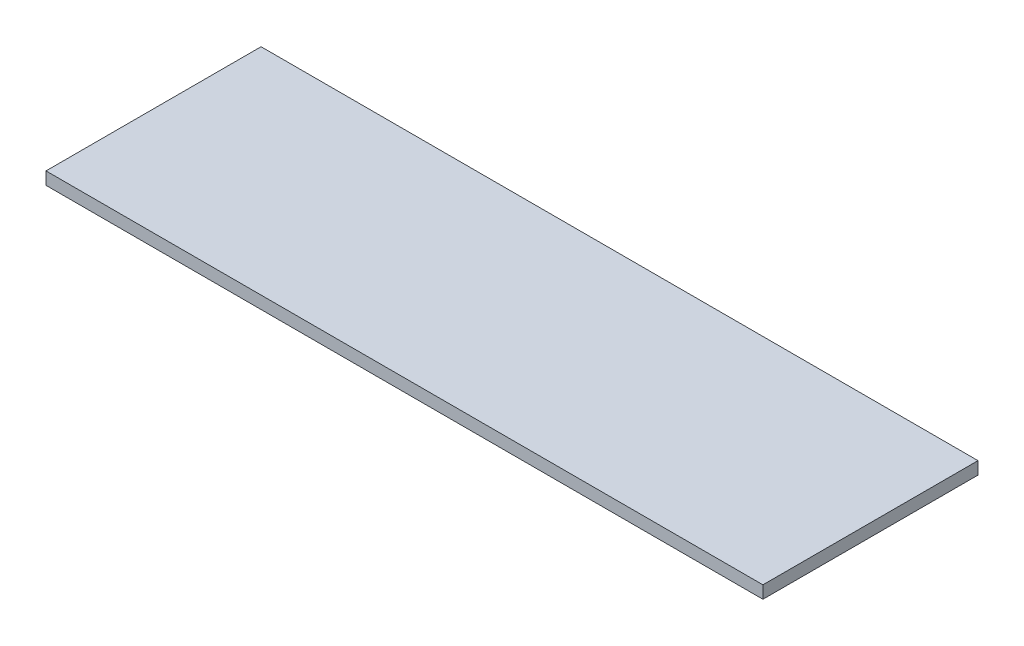
from build123d import *

# Parameters (mm, degrees)
SKETCH1_W           = 2000
SKETCH1_H           = 600
BOSS_EXTRUDE1_DEPTH = 35


with BuildPart() as part:
    # Sketch1 → Boss-Extrude1 (new body)
    with BuildSketch(Plane(origin=(0, 0, 0), x_dir=(1, 0, 0), z_dir=(0, 1, 0))):
        with Locations((6.124906714, 58.016168427)):
            Rectangle(SKETCH1_W, SKETCH1_H)
    extrude(amount=BOSS_EXTRUDE1_DEPTH)


solid = part.part
